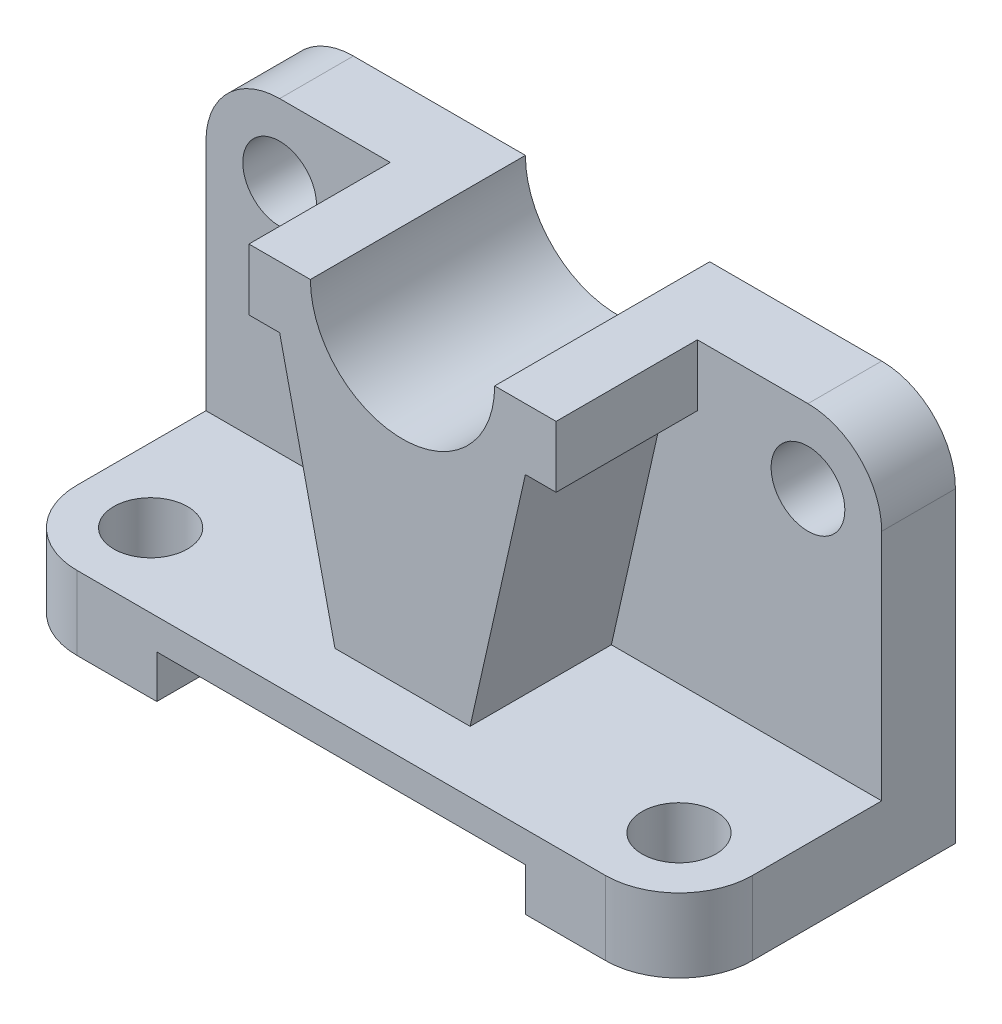
from build123d import *

# Parameters (mm, degrees)
BOSS_EXTRUDE1_DEPTH = 110
FILLET1_R           = 12
SKETCH2_R           = 6
CUT_EXTRUDE1_DEPTH  = 12
SKETCH3_R           = 6
CUT_EXTRUDE3_DEPTH  = 12
SKETCH4_W           = 60
SKETCH4_H           = 7
CUT_EXTRUDE4_DEPTH  = 60
BOSS_EXTRUDE2_DEPTH = 35
CUT_EXTRUDE5_DEPTH  = 35


with BuildPart() as part:
    # Sketch1 → Boss-Extrude1 (new body)
    with BuildSketch(Plane(origin=(0, 0, 0), x_dir=(0, 0, -1), z_dir=(1, 0, 0))):
        Polygon((10.424266139, 39.165457063), (22.424266139, 39.165457063), (22.424266139, -22.834542937), (-22.575733861, -22.834542937), (-22.575733861, -10.834542937), (10.424266139, -10.834542937), align=None)
    extrude(amount=BOSS_EXTRUDE1_DEPTH)

    # Fillet1
    fillet1_edges = [part.edges().sort_by_distance(p)[0] for p in [
        (110, -16.834542937, 22.575733861),
        (0, -16.834542937, 22.575733861),
        (110, 39.165457063, -16.424266139),
        (0, 39.165457063, -16.424266139),
    ]]
    fillet(fillet1_edges, radius=FILLET1_R)

    # Sketch2 → Cut-Extrude1 (cut)
    with BuildSketch(Plane(origin=(0, -10.834542937, 0), x_dir=(1, 0, 0), z_dir=(0, 1, 0))):
        with Locations(Location((12, -10.575733861, 0), (0, 0, 270))):
            Circle(SKETCH2_R)
        with Locations(Location((98, -10.575733861, 0), (0, 0, 270))):
            Circle(SKETCH2_R)
    extrude(amount=-CUT_EXTRUDE1_DEPTH, mode=Mode.SUBTRACT)

    # Sketch3 → Cut-Extrude3 (cut)
    with BuildSketch(Plane.XY.offset(-10.424266139)):
        with Locations((12, 27.165457063)):
            Circle(SKETCH3_R)
        with Locations((98, 27.165457063)):
            Circle(SKETCH3_R)
    extrude(amount=-CUT_EXTRUDE3_DEPTH, mode=Mode.SUBTRACT)

    # Sketch4 → Cut-Extrude4 (cut)
    with BuildSketch(Plane.XY.offset(22.575733861)):
        with Locations((55, -19.334542937)):
            Rectangle(SKETCH4_W, SKETCH4_H)
    extrude(amount=-CUT_EXTRUDE4_DEPTH, mode=Mode.SUBTRACT)

    # 3DSketch1 → Boss-Extrude2 (add)
    with BuildSketch(Plane(origin=(30, 39.165457063, -22.424266139), x_dir=(0.5843189672224485, -0.8115240874700463, 0), z_dir=(0, 0, 1))):
        with BuildLine():
            Line((0, 0), (5.843189672, 8.115240875))
            ThreePointArc((5.843189672, 8.115240875), (26.780835493, 11.523317678), (23.372758689, 32.460963499))
            Line((23.372758689, 32.460963499), (29.215948361, 40.576204374))
            Line((29.215948361, 40.576204374), (37.331189236, 34.733014701))
            Line((37.331189236, 34.733014701), (34.4095944, 30.675394264))
            Line((34.4095944, 30.675394264), (61.610185565, 0))
            Line((61.610185565, 0), (48.755168287, -17.853529924))
            Line((48.755168287, -17.853529924), (11.036835711, -1.785569235))
            Line((11.036835711, -1.785569235), (8.115240875, -5.843189672))
            Line((8.115240875, -5.843189672), (0, 0))
        make_face()
    extrude(amount=BOSS_EXTRUDE2_DEPTH)

    # Sketch5 → Cut-Extrude5 (cut)
    with BuildSketch(Plane.XY.offset(-10.424266139)):
        with BuildLine():
            Line((40, 39.165457063), (70, 39.165457063))
            ThreePointArc((70, 39.165457063), (55, 24.165457063), (40, 39.165457063))
        make_face()
    extrude(amount=-CUT_EXTRUDE5_DEPTH, mode=Mode.SUBTRACT)


solid = part.part
